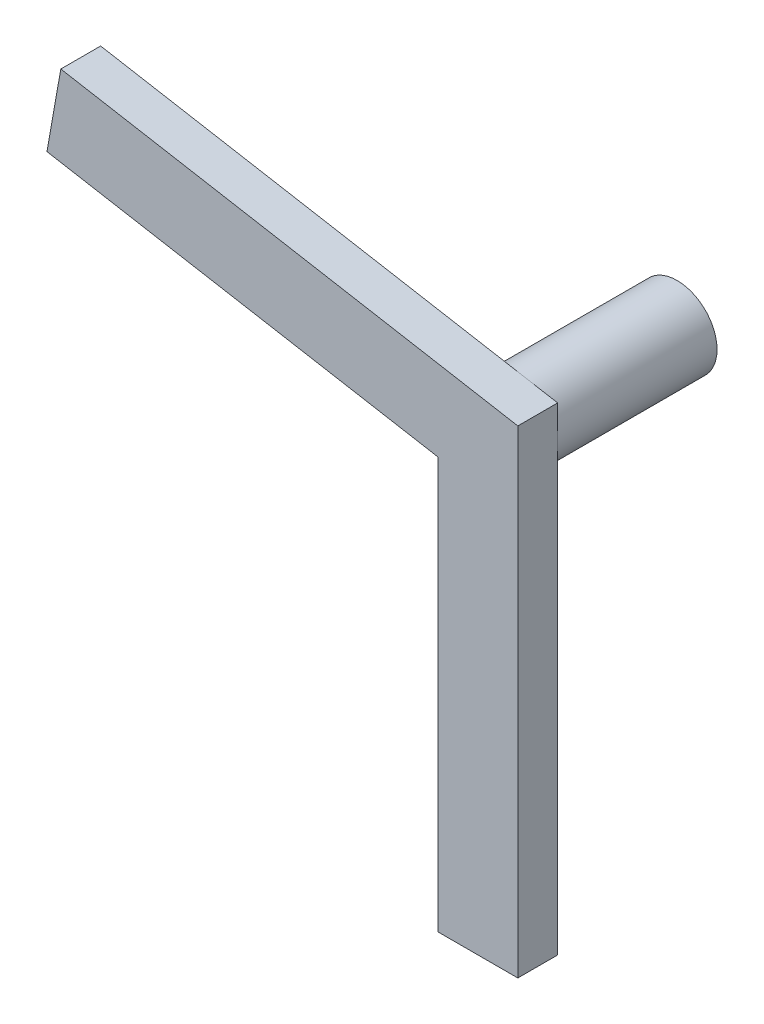
from build123d import *

# Parameters (mm, degrees)
BOSS_EXTRU_1_DEPTH = 5
ESQUISSE2_R        = 5
BOSS_EXTRU_2_DEPTH = 20


with BuildPart() as part:
    # Esquisse1 → Boss.-Extru.1 (new body)
    with BuildSketch(Plane.XY):
        Polygon((5, -5.958767963), (-5, -4.195498156), (-5, -55.804501844), (5, -55.804501844), align=None)
        Polygon((-52.351983404, 14.308200227), (-54.088465181, 4.460122697), (-5, -4.195498156), (5, -5.958767963), (5, 4.195498156), align=None)
    extrude(amount=BOSS_EXTRU_1_DEPTH)

    # Esquisse2 → Boss.-Extru.2 (add)
    with BuildSketch(Plane(origin=(0, 0, 0), x_dir=(-1, 0, 0), z_dir=(0, 0, -1))):
        Circle(ESQUISSE2_R)
    extrude(amount=BOSS_EXTRU_2_DEPTH)


solid = part.part
